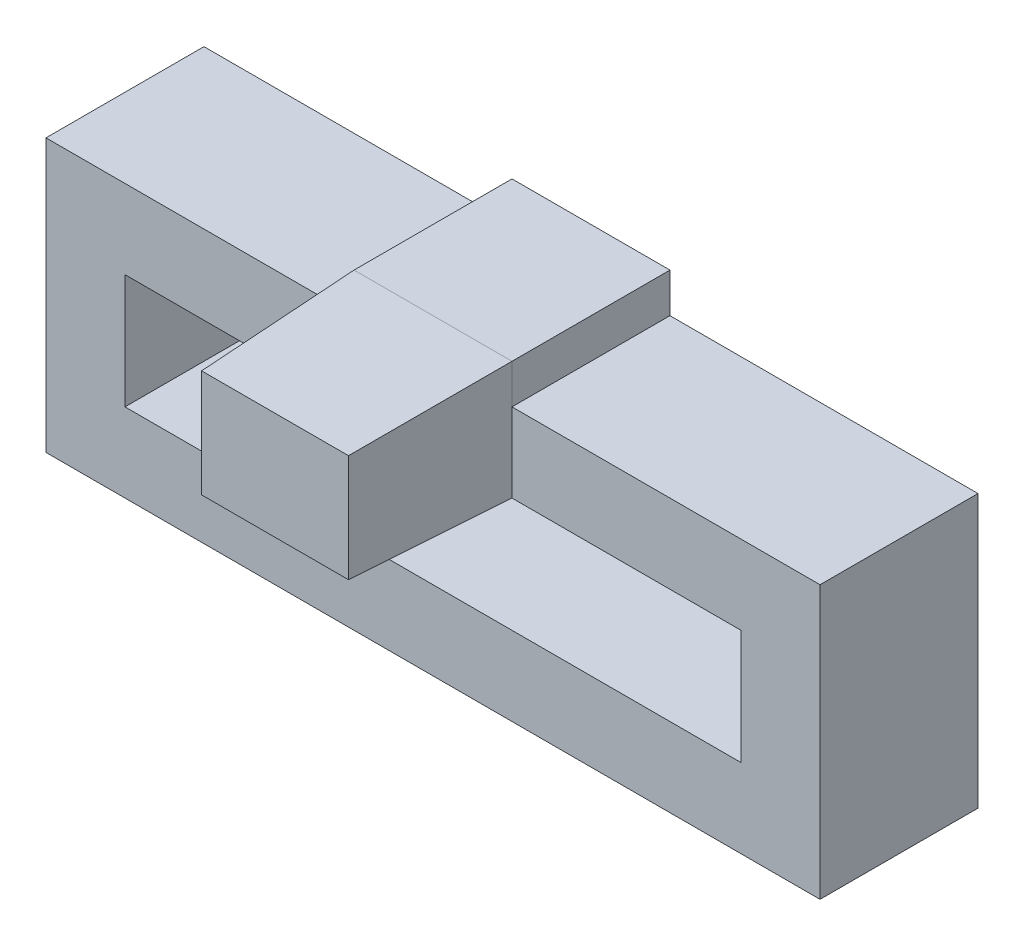
from build123d import *

# Parameters (mm, degrees)
ESQUISSE1_W        = 19.6
ESQUISSE1_H        = 6.9
ESQUISSE1_W_2      = 15.6
ESQUISSE1_H_2      = 2.9
EXTRU_MINCE1_DEPTH = 4
ESQUISSE2_W        = 4
ESQUISSE2_H        = 3
BOSS_EXTRU_2_DEPTH = 4
ESQUISSE3_W        = 4
ESQUISSE3_H        = 3
BOSS_EXTRU_3_DEPTH = 4
BOSS_EXTRU_3_TAPER = 2


with BuildPart() as part:
    # Esquisse1 → Extru.-Mince1 (new body)
    with BuildSketch(Plane.XY):
        with Locations((7.8, 1.45)):
            Rectangle(ESQUISSE1_W, ESQUISSE1_H)
        with Locations((7.8, 1.45)):
            Rectangle(ESQUISSE1_W_2, ESQUISSE1_H_2, mode=Mode.SUBTRACT)
    extrude(amount=EXTRU_MINCE1_DEPTH)

    # Esquisse2 → Boss.-Extru.2 (add)
    with BuildSketch(Plane.XY):
        with Locations((7.8, 4.4)):
            Rectangle(ESQUISSE2_W, ESQUISSE2_H)
    extrude(amount=BOSS_EXTRU_2_DEPTH)

    # Esquisse3 → Boss.-Extru.3 (add)
    with BuildSketch(Plane.XY.offset(4)):
        with Locations((7.8, 4.4)):
            Rectangle(ESQUISSE3_W, ESQUISSE3_H)
    extrude(amount=BOSS_EXTRU_3_DEPTH, taper=BOSS_EXTRU_3_TAPER)


solid = part.part
